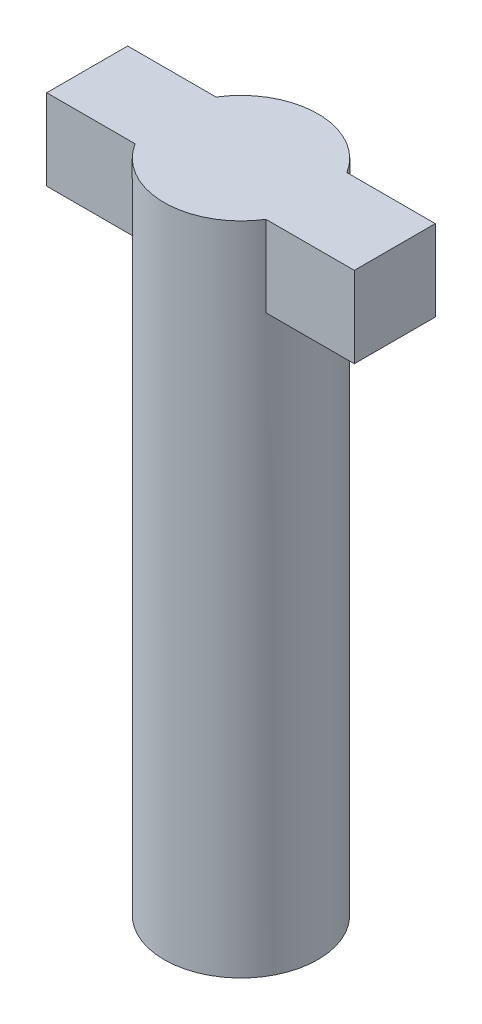
from build123d import *

# Parameters (mm, degrees)
SKETCH1_R  = 0.95
BODY_DEPTH = 8.1
LOCK_DEPTH = 1


with BuildPart() as part:
    # Sketch1 → Body (new body)
    with BuildSketch(Plane(origin=(0, 0, 0), x_dir=(1, 0, 0), z_dir=(0, 1, 0))):
        Circle(SKETCH1_R)
    extrude(amount=BODY_DEPTH)

    # Sketch2 → Lock (add)
    with BuildSketch(Plane(origin=(0, 8.1, 0), x_dir=(1, 0, 0), z_dir=(0, 1, 0))):
        with BuildLine():
            ThreePointArc((-0.807774721, -0.5), (-0.95, 0), (-0.807774721, 0.5))
            Line((-0.807774721, 0.5), (-1.9, 0.5))
            Line((-1.9, 0.5), (-1.9, -0.5))
            Line((-1.9, -0.5), (-0.807774721, -0.5))
        make_face()
        with BuildLine():
            Line((1.9, 0.5), (0.807774721, 0.5))
            ThreePointArc((0.807774721, 0.5), (0.91375215, 0.259917309), (0.95, 0))
            ThreePointArc((0.95, 0), (0.91375215, -0.259917309), (0.807774721, -0.5))
            Line((0.807774721, -0.5), (1.9, -0.5))
            Line((1.9, -0.5), (1.9, 0.5))
        make_face()
    extrude(amount=-LOCK_DEPTH)


solid = part.part
